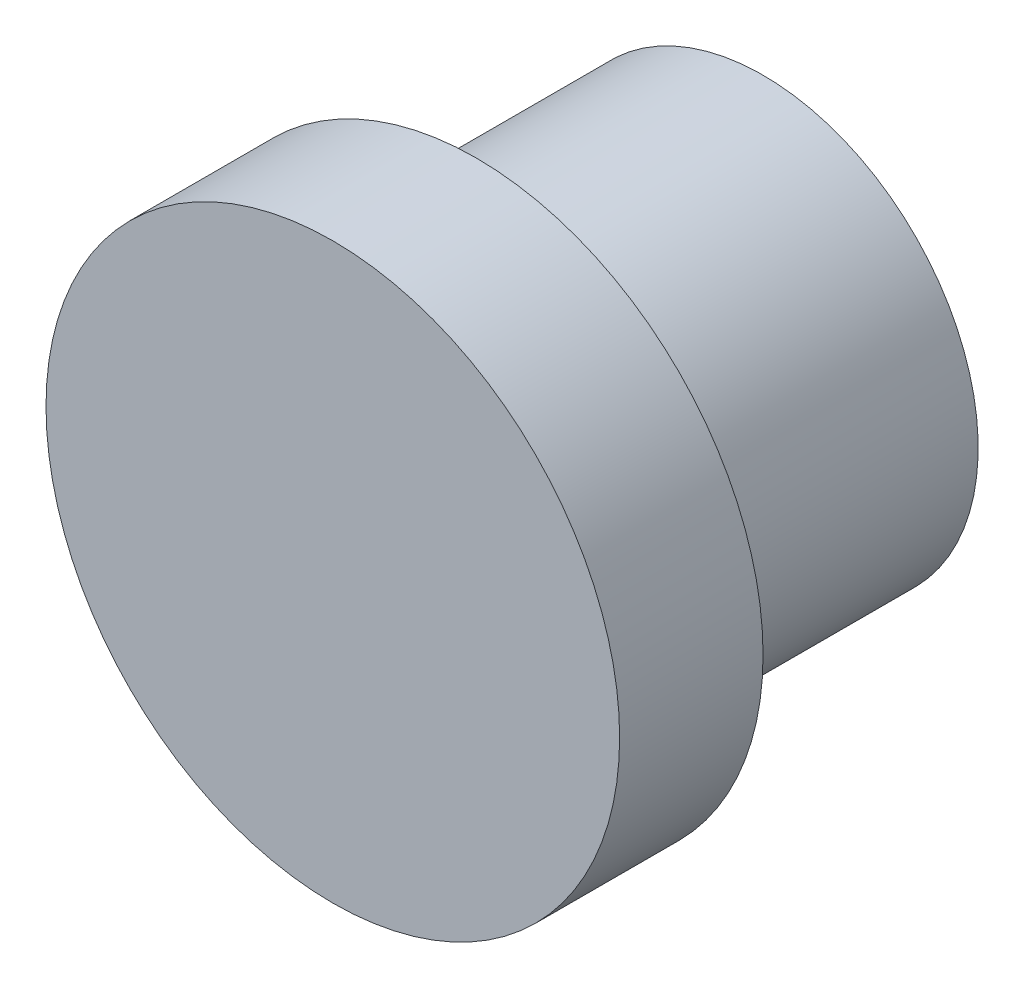
from build123d import *

# Parameters (mm, degrees)
SKETCH_1_R          = 8
EXTRUDE_1_DEPTH     = 12
SKETCH_2_OUTSIDE_W  = 23.122
SKETCH_2_OUTSIDE_H  = 23.122
SKETCH_2_OUTSIDE_R  = 6
CUT_EXTRUDE_1_DEPTH = 8


with BuildPart() as part:
    # Эскиз1 → Бобышка-Вытянуть1 (new body)
    with BuildSketch(Plane.XY):
        Circle(SKETCH_1_R)
    extrude(amount=EXTRUDE_1_DEPTH)

    # Эскиз2 outside → Вырез-Вытянуть1 (cut)
    with BuildSketch(Plane(origin=(0, 0, 0), x_dir=(-1, 0, 0), z_dir=(0, 0, -1))):
        Rectangle(SKETCH_2_OUTSIDE_W, SKETCH_2_OUTSIDE_H)
        Circle(SKETCH_2_OUTSIDE_R, mode=Mode.SUBTRACT)
    extrude(amount=-CUT_EXTRUDE_1_DEPTH, mode=Mode.SUBTRACT)


solid = part.part
